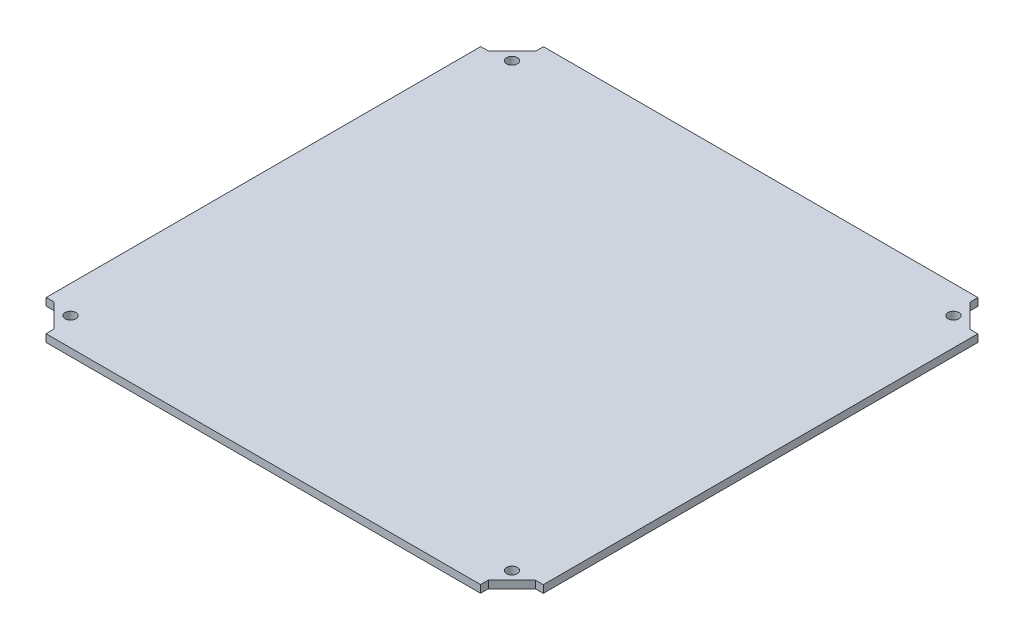
from build123d import *

# Parameters (mm, degrees)
BOSS_EXTRUDE1_DEPTH = 3.175
CUT_EXTRUDE1_REACH  = 5.175
SKETCH3_R           = 2.286


with BuildPart() as part:
    # Sketch1 → Boss-Extrude1 (new body)
    with BuildSketch(Plane(origin=(0, 0, 0), x_dir=(1, 0, 0), z_dir=(0, 1, 0))):
        Polygon((-91.233267746, 104.4575), (-91.233267746, 101.1555), (-101.1555, 91.321365209), (-104.4575, 91.321365209), (-104.4575, -91.233267746), (-101.1555, -91.233267746), (-91.321365209, -101.1555), (-91.321365209, -104.4575), (91.233267746, -104.4575), (91.233267746, -101.1555), (101.1555, -91.321365209), (104.4575, -91.321365209), (104.4575, 91.233267746), (101.1555, 91.233267746), (91.321365209, 101.1555), (91.321365209, 104.4575), align=None)
    extrude(amount=BOSS_EXTRUDE1_DEPTH)

    # Sketch3 → Cut-Extrude1 (cut, up to next)
    with BuildSketch(Plane(origin=(0, 3.175, 0), x_dir=(1, 0, 0), z_dir=(0, 1, 0)), mode=Mode.PRIVATE) as cut_extrude1_sk1:
        with Locations((-92.73413, 92.73413)):
            Circle(SKETCH3_R)
    cut_extrude1_tool1 = extrude(cut_extrude1_sk1.sketch, amount=-CUT_EXTRUDE1_REACH, mode=Mode.PRIVATE) & part.part
    add(cut_extrude1_tool1.solids().sort_by_distance((-92.73413, 3.175, -92.73413))[0], mode=Mode.SUBTRACT)
    # Sketch3 → Cut-Extrude1 (cut, up to next)
    with BuildSketch(Plane(origin=(0, 3.175, 0), x_dir=(1, 0, 0), z_dir=(0, 1, 0)), mode=Mode.PRIVATE) as cut_extrude1_sk2:
        with Locations((92.73413, 92.73413)):
            Circle(SKETCH3_R)
    cut_extrude1_tool2 = extrude(cut_extrude1_sk2.sketch, amount=-CUT_EXTRUDE1_REACH, mode=Mode.PRIVATE) & part.part
    add(cut_extrude1_tool2.solids().sort_by_distance((92.73413, 3.175, -92.73413))[0], mode=Mode.SUBTRACT)
    # Sketch3 → Cut-Extrude1 (cut, up to next)
    with BuildSketch(Plane(origin=(0, 3.175, 0), x_dir=(1, 0, 0), z_dir=(0, 1, 0)), mode=Mode.PRIVATE) as cut_extrude1_sk3:
        with Locations((92.73413, -92.73413)):
            Circle(SKETCH3_R)
    cut_extrude1_tool3 = extrude(cut_extrude1_sk3.sketch, amount=-CUT_EXTRUDE1_REACH, mode=Mode.PRIVATE) & part.part
    add(cut_extrude1_tool3.solids().sort_by_distance((92.73413, 3.175, 92.73413))[0], mode=Mode.SUBTRACT)
    # Sketch3 → Cut-Extrude1 (cut, up to next)
    with BuildSketch(Plane(origin=(0, 3.175, 0), x_dir=(1, 0, 0), z_dir=(0, 1, 0)), mode=Mode.PRIVATE) as cut_extrude1_sk4:
        with Locations((-92.73413, -92.73413)):
            Circle(SKETCH3_R)
    cut_extrude1_tool4 = extrude(cut_extrude1_sk4.sketch, amount=-CUT_EXTRUDE1_REACH, mode=Mode.PRIVATE) & part.part
    add(cut_extrude1_tool4.solids().sort_by_distance((-92.73413, 3.175, 92.73413))[0], mode=Mode.SUBTRACT)


solid = part.part
